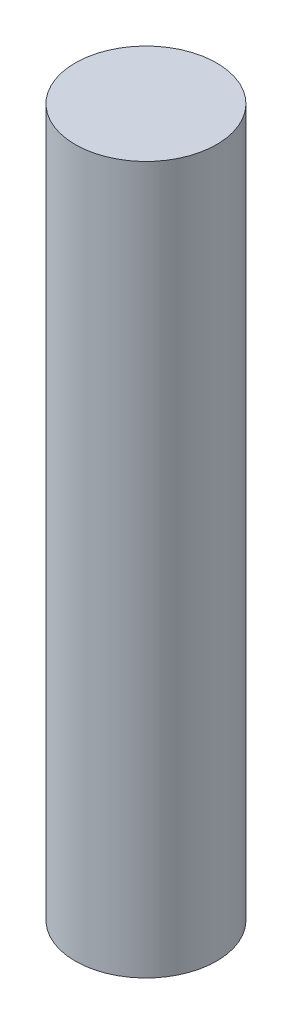
from build123d import *

# Parameters (mm, degrees)
SKETCH1_R           = 0.79375
BOSS_EXTRUDE1_DEPTH = 7.9375


with BuildPart() as part:
    # Sketch1 → Boss-Extrude1 (new body)
    with BuildSketch(Plane(origin=(0, 0, 0), x_dir=(1, 0, 0), z_dir=(0, 1, 0))):
        Circle(SKETCH1_R)
    extrude(amount=BOSS_EXTRUDE1_DEPTH)


solid = part.part
